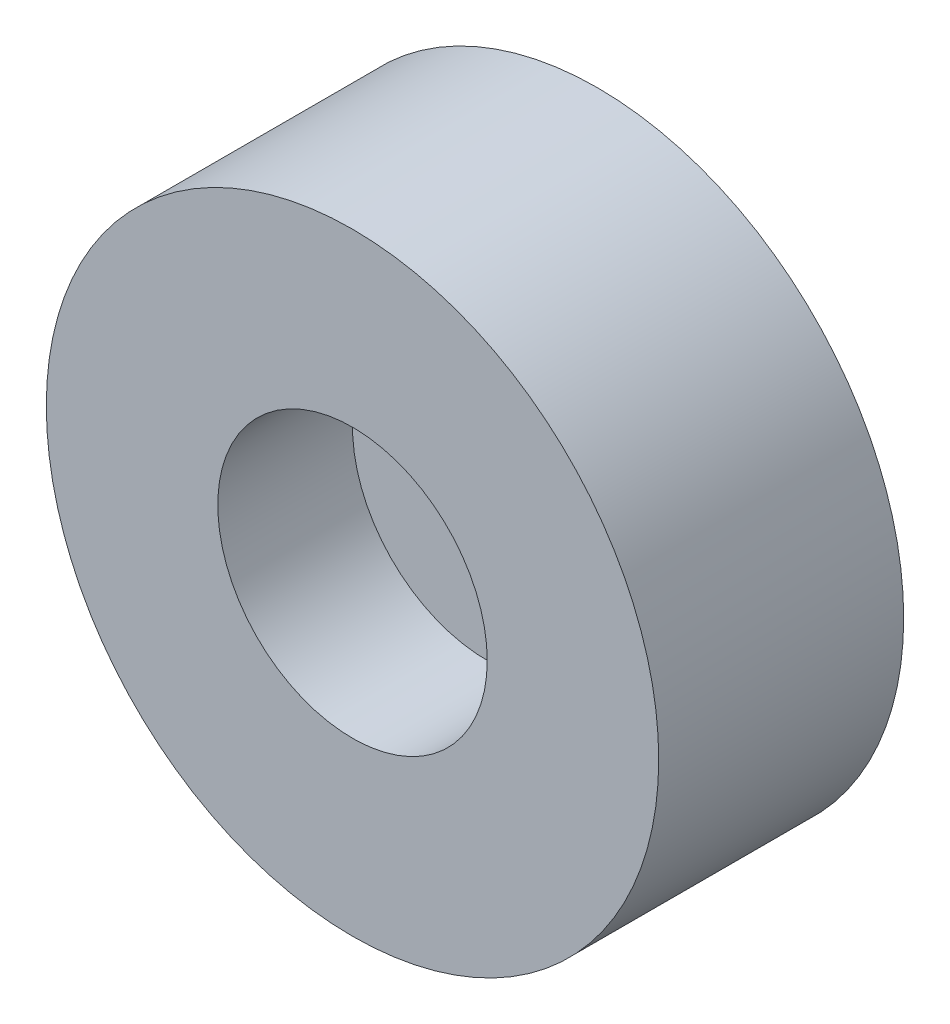
from build123d import *

# Parameters (mm, degrees)
SKETCH1_R           = 6.35
BOSS_EXTRUDE1_DEPTH = 5.08
SKETCH2_R           = 2.794
CUT_EXTRUDE1_DEPTH  = 2.794


with BuildPart() as part:
    # Sketch1 → Boss-Extrude1 (new body)
    with BuildSketch(Plane.XY):
        Circle(SKETCH1_R)
    extrude(amount=BOSS_EXTRUDE1_DEPTH)

    # Sketch2 → Cut-Extrude1 (cut)
    with BuildSketch(Plane.XY.offset(5.08)):
        Circle(SKETCH2_R)
    extrude(amount=-CUT_EXTRUDE1_DEPTH, mode=Mode.SUBTRACT)


solid = part.part
